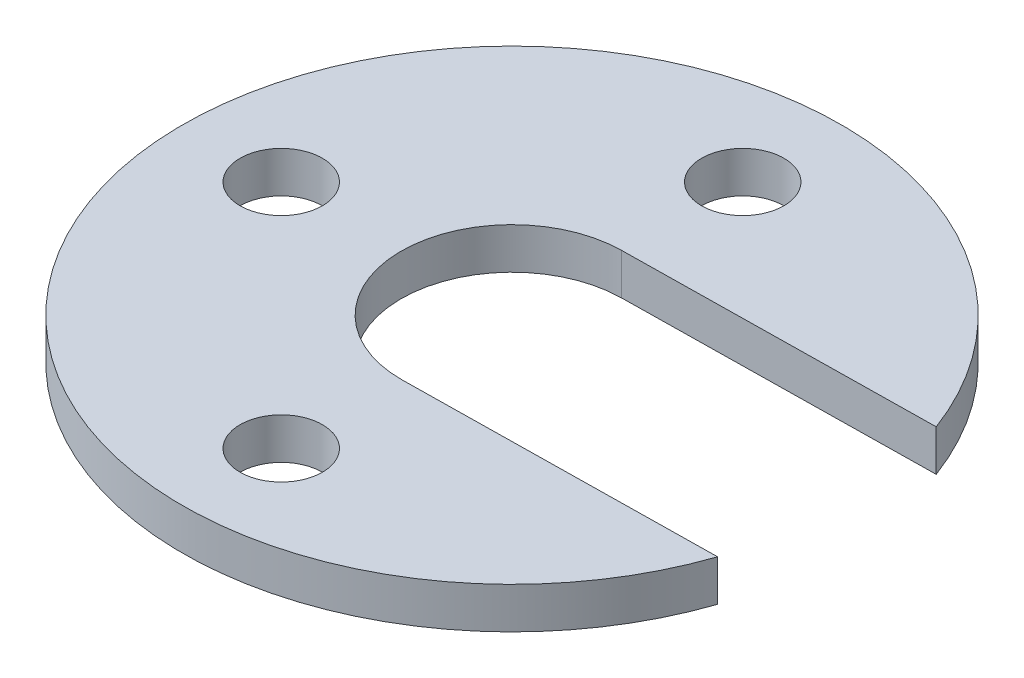
from build123d import *

# Parameters (mm, degrees)
SKETCH1_R           = 5
BOSS_EXTRUDE1_DEPTH = 5


with BuildPart() as part:
    # Sketch1 → Boss-Extrude1 (new body)
    with BuildSketch(Plane(origin=(0, 0, 0), x_dir=(1, 0, 0), z_dir=(0, 1, 0))):
        with BuildLine():
            Line((-0.197255311, 13.462674969), (37.46456841, 14.014496562))
            ThreePointArc((37.46456841, 14.014496562), (-39.995707061, -0.586017686), (37.859079031, -12.910853376))
            Line((37.859079031, -12.910853376), (0.197255311, -13.462674969))
            ThreePointArc((0.197255311, -13.462674969), (-13.462674969, -0.197255311), (-0.197255311, 13.462674969))
        make_face()
        with Locations((0, 28)):
            Circle(SKETCH1_R, mode=Mode.SUBTRACT)
        with Locations((-28, 0)):
            Circle(SKETCH1_R, mode=Mode.SUBTRACT)
        with Locations((0, -28)):
            Circle(SKETCH1_R, mode=Mode.SUBTRACT)
    extrude(amount=BOSS_EXTRUDE1_DEPTH)


solid = part.part
